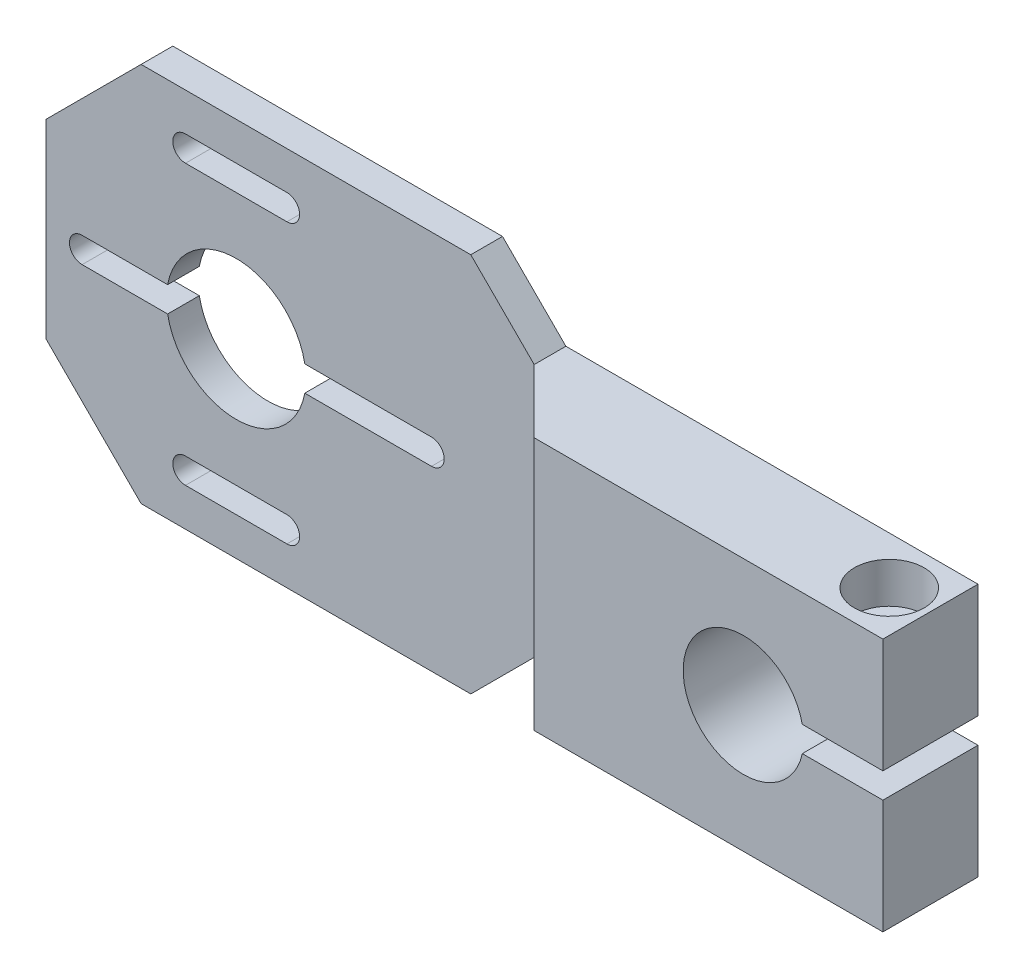
from build123d import *

# Parameters (mm, degrees)
ESQUISSE1_R                                        = 11
BOSS_EXTRU_1_DEPTH                                 = 15
CHAMBRAGE_POUR_VIS_T_TE_HEXAGONALE_M61_D           = 6.6
CHAMBRAGE_POUR_VIS_T_TE_HEXAGONALE_M61_DEPTH       = 18
CHAMBRAGE_POUR_VIS_T_TE_HEXAGONALE_M61_CBORE_D     = 11
CHAMBRAGE_POUR_VIS_T_TE_HEXAGONALE_M61_CBORE_DEPTH = 6.4
ENL_V_MAT_EXTRU_7_DEPTH                            = 91
TROU_TARAUD_M61_D                                  = 5
ENL_V_MAT_EXTRU_8_DEPTH                            = 6


with BuildPart() as part:
    # Esquisse1 → Boss.-Extru.1 (new body)
    with BuildSketch(Plane.XY):
        with BuildLine():
            Line((37, 30), (47, 20))
            Line((47, 20), (112, 20))
            Line((112, 20), (112, 2))
            Line((112, 2), (99.287087811, 2))
            ThreePointArc((99.287087811, 2), (80.5, 0), (99.287087811, -2))
            Line((99.287087811, -2), (112, -2))
            Line((112, -2), (112, -20))
            Line((112, -20), (47, -20))
            Line((47, -20), (37, -30))
            Line((37, -30), (-15, -30))
            Line((-15, -30), (-30, -15))
            Line((-30, -15), (-30, 15))
            Line((-30, 15), (-15, 30))
            Line((-15, 30), (37, 30))
        make_face()
        Circle(ESQUISSE1_R, mode=Mode.SUBTRACT)
        with BuildLine():
            Line((-8, 24), (8, 24))
            ThreePointArc((8, 24), (10, 22), (8, 20))
            Line((8, 20), (-8, 20))
            ThreePointArc((-8, 20), (-10, 22), (-8, 24))
        make_face(mode=Mode.SUBTRACT)
        with BuildLine():
            Line((-8, -24), (8, -24))
            ThreePointArc((8, -24), (10, -22), (8, -20))
            Line((8, -20), (-8, -20))
            ThreePointArc((-8, -20), (-10, -22), (-8, -24))
        make_face(mode=Mode.SUBTRACT)
    extrude(amount=BOSS_EXTRU_1_DEPTH)

    # Chambrage pour vis à tête hexagonale M61
    with Locations(Plane(origin=(0, 20, 0), x_dir=(-1, 0, 0), z_dir=(0, 1, 0))):
        with Locations((-105.5, 7.5)):
            CounterBoreHole(CHAMBRAGE_POUR_VIS_T_TE_HEXAGONALE_M61_D / 2, CHAMBRAGE_POUR_VIS_T_TE_HEXAGONALE_M61_CBORE_D / 2, CHAMBRAGE_POUR_VIS_T_TE_HEXAGONALE_M61_CBORE_DEPTH, depth=CHAMBRAGE_POUR_VIS_T_TE_HEXAGONALE_M61_DEPTH)

    # Esquisse4 → Enlèv. mat.-Extru.7 (cut, through all)
    with BuildSketch(Plane(origin=(0, 60, 0), x_dir=(1, 0, 0), z_dir=(0, 1, 0))):
        Polygon((47, -5), (-30, -5), (-30, -38.86865167), (80.86865167, -38.86865167), align=None)
    extrude(amount=-ENL_V_MAT_EXTRU_7_DEPTH, mode=Mode.SUBTRACT)

    # Trou taraudé M61 (through all)
    with Locations(Plane(origin=(0, -2, 0), x_dir=(1, 0, 0), z_dir=(0, 1, 0))):
        with Locations((105.5, -7.5)):
            Hole(TROU_TARAUD_M61_D / 2)

    # Esquisse7 → Enlèv. mat.-Extru.8 (cut, through all)
    with BuildSketch(Plane.XY.offset(5)):
        with BuildLine():
            Line((-24.3, 2), (-6.3, 2))
            ThreePointArc((-6.3, 2), (-4.3, 0), (-6.3, -2))
            Line((-6.3, -2), (-24.3, -2))
            ThreePointArc((-24.3, -2), (-26.3, 0), (-24.3, 2))
        make_face()
        with BuildLine():
            Line((8.8, 2), (30.8, 2))
            ThreePointArc((30.8, 2), (32.8, 0), (30.8, -2))
            Line((30.8, -2), (8.8, -2))
            ThreePointArc((8.8, -2), (6.8, 0), (8.8, 2))
        make_face()
    extrude(amount=-ENL_V_MAT_EXTRU_8_DEPTH, mode=Mode.SUBTRACT)


solid = part.part
